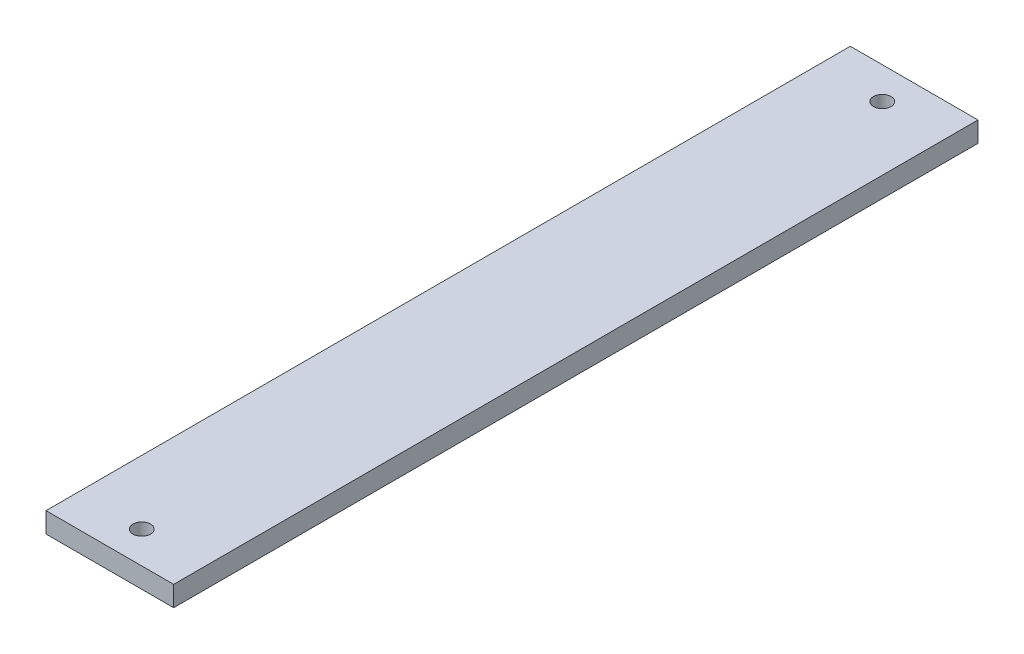
from build123d import *

# Parameters (mm, degrees)
SKETCH1_W           = 40
SKETCH1_H           = 252
SKETCH1_R           = 2.75
BOSS_EXTRUDE1_DEPTH = 6.35


with BuildPart() as part:
    # Sketch1 → Boss-Extrude1 (new body)
    with BuildSketch(Plane(origin=(0, 0, 0), x_dir=(1, 0, 0), z_dir=(0, 1, 0))):
        Rectangle(SKETCH1_W, SKETCH1_H)
        with Locations((0, -116)):
            Circle(SKETCH1_R, mode=Mode.SUBTRACT)
        with Locations((0, 116)):
            Circle(SKETCH1_R, mode=Mode.SUBTRACT)
    extrude(amount=BOSS_EXTRUDE1_DEPTH)


solid = part.part
